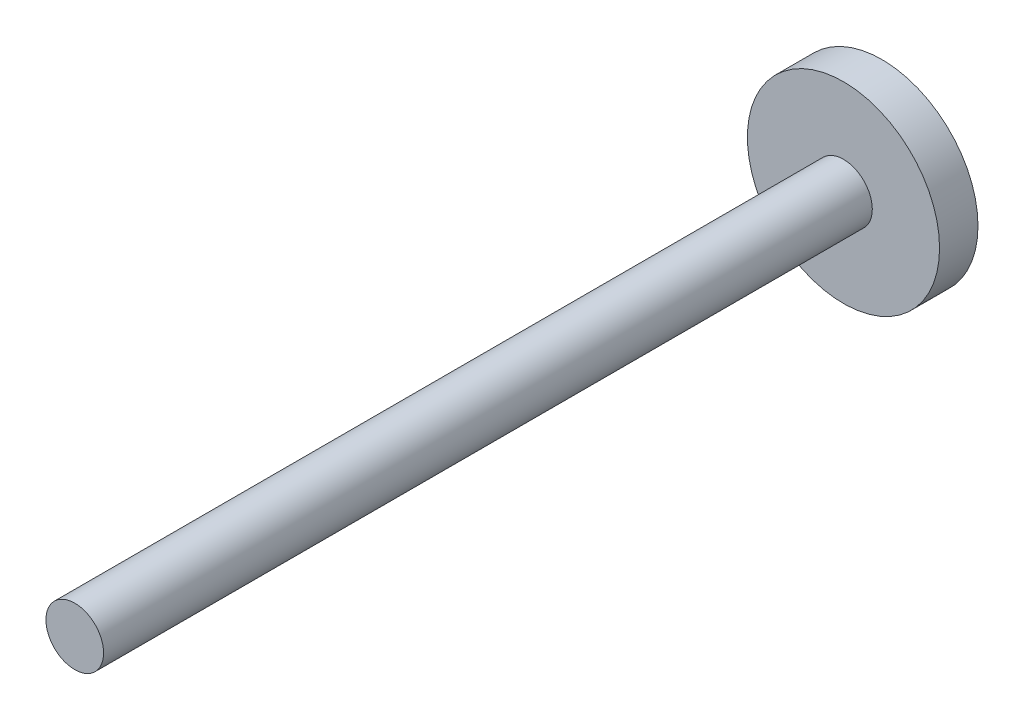
from build123d import *

# Parameters (mm, degrees)
SKETCH1_R           = 10
BOSS_EXTRUDE1_DEPTH = 4
SKETCH2_R           = 3
BOSS_EXTRUDE2_DEPTH = 80
CUT_EXTRUDE1_DEPTH  = 2


with BuildPart() as part:
    # Sketch1 → Boss-Extrude1 (new body)
    with BuildSketch(Plane.XY):
        Circle(SKETCH1_R)
    extrude(amount=BOSS_EXTRUDE1_DEPTH)

    # Sketch2 → Boss-Extrude2 (add)
    with BuildSketch(Plane.XY.offset(4)):
        Circle(SKETCH2_R)
    extrude(amount=BOSS_EXTRUDE2_DEPTH)

    # Sketch3 → Cut-Extrude1 (cut)
    with BuildSketch(Plane(origin=(0, 0, 0), x_dir=(-1, 0, 0), z_dir=(0, 0, -1))):
        Polygon((-4.148384256, 7.097061567), (-8.220427737, -0.044075367), (-4.072043481, -7.141136934), (4.148384256, -7.097061567), (8.220427737, 0.044075367), (4.072043481, 7.141136934), align=None)
    extrude(amount=-CUT_EXTRUDE1_DEPTH, mode=Mode.SUBTRACT)


solid = part.part
